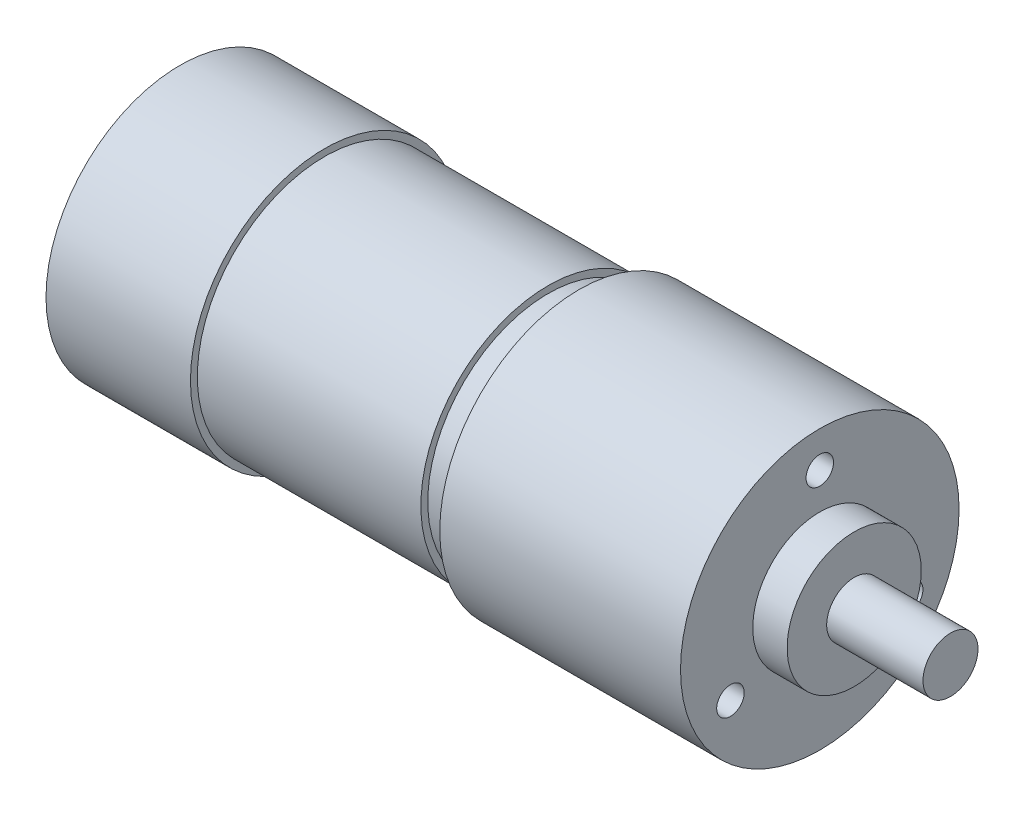
from build123d import *

# Parameters (mm, degrees)
SCHIZZO4_R               = 2
TAGLIO_ESTRUSIONE1_DEPTH = 8


with BuildPart() as part:
    # Schizzo3 → Rivoluzione1 (revolve)
    with BuildSketch(Plane(origin=(0, 0, 0), x_dir=(1, 0, 0), z_dir=(0, 1, 0))):
        Polygon((0, 0), (0, 19.5), (21, 19.5), (21, 18.5), (53.5, 18.5), (53.5, 17.5), (58, 17.5), (58, 20.25), (93, 20.25), (93, 9.75), (98, 9.75), (98, 4), (112, 4), (112, 0), align=None)
    revolve(axis=Axis((112, 0, 0), (-1, 0, 0)))

    # Schizzo4 → Taglio-Estrusione1 (cut)
    with BuildSketch(Plane(origin=(93, 0, 0), x_dir=(0, 0, -1), z_dir=(1, 0, 0))):
        with Locations((0, 15)):
            Circle(SCHIZZO4_R)
        with Locations((12.990381057, -7.5)):
            Circle(SCHIZZO4_R)
        with Locations((-12.990381057, -7.5)):
            Circle(SCHIZZO4_R)
    extrude(amount=-TAGLIO_ESTRUSIONE1_DEPTH, mode=Mode.SUBTRACT)


solid = part.part
